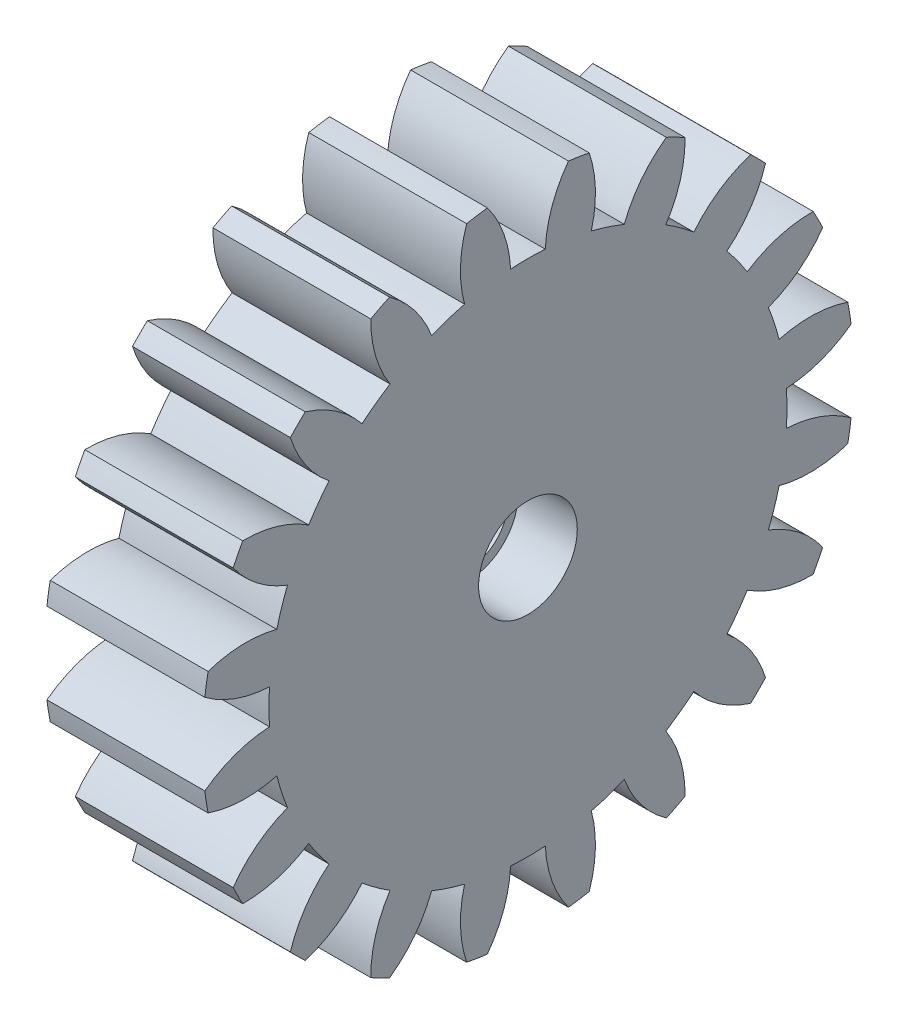
from build123d import *

# Parameters (mm, degrees)
BASPROSKE_W        = 8
BASPROSKE_H        = 16.5
TOOTHCUT_DEPTH     = 25.667792767
TEETHCUTS_COUNT    = 20
TEETHCUTS_ANGLE    = 342
BORSKE_R           = 2
BORE_DEPTH         = 50.0000508
SKETCH1_R          = 2.5
CUT_EXTRUDE1_DEPTH = 3


with BuildPart() as part:
    # BasProSke → Base-Revolve (revolve)
    with BuildSketch(Plane(origin=(0, 0, 0), x_dir=(1, 0, 0), z_dir=(0, 1, 0)), mode=Mode.PRIVATE) as base_revolve_sk:
        with Locations((4, 8.25)):
            Rectangle(BASPROSKE_W, BASPROSKE_H)
    revolve(base_revolve_sk.sketch.rotate(Axis((-10, 0, 0), (1, 0, 0)), 180), axis=Axis((-10, 0, 0), (1, 0, 0)))

    # TooCutSke → ToothCut (cut, through all)
    with BuildSketch(Plane(origin=(0, 0, 0), x_dir=(0, 0, -1), z_dir=(1, 0, 0))):
        with BuildLine():
            ThreePointArc((0.877929023, 13.094602576), (0, 13.124), (-0.877929023, 13.094602576))
            ThreePointArc((-0.877929023, 13.094602576), (-1.227785764, 14.834041313), (-2.071065599, 16.395106966))
            ThreePointArc((-2.071065599, 16.395106966), (0, 16.5254), (2.071065599, 16.395106966))
            ThreePointArc((2.071065599, 16.395106966), (1.227785764, 14.834041313), (0.877929023, 13.094602576))
        make_face()
    toothcut = extrude(amount=TOOTHCUT_DEPTH, mode=Mode.SUBTRACT)

    # TeethCuts: ToothCut ×20 about axis
    teethcuts_axis = Axis((-10, 0, 0), (1, 0, 0))
    for i in range(1, TEETHCUTS_COUNT):
        add(toothcut.rotate(teethcuts_axis, i * TEETHCUTS_ANGLE / (TEETHCUTS_COUNT - 1)), mode=Mode.SUBTRACT)

    # BorSke → Bore (cut, symmetric)
    with BuildSketch(Plane(origin=(0, 0, 0), x_dir=(0, 0, -1), z_dir=(1, 0, 0))):
        with Locations(Location((0, 0, 0), (0, 0, 180))):
            Circle(BORSKE_R)
    extrude(amount=BORE_DEPTH, both=True, mode=Mode.SUBTRACT)

    # Sketch1 → Cut-Extrude1 (cut)
    with BuildSketch(Plane(origin=(8, 0, 0), x_dir=(0, 0, -1), z_dir=(1, 0, 0))):
        Circle(SKETCH1_R)
    extrude(amount=-CUT_EXTRUDE1_DEPTH, mode=Mode.SUBTRACT)


solid = part.part
